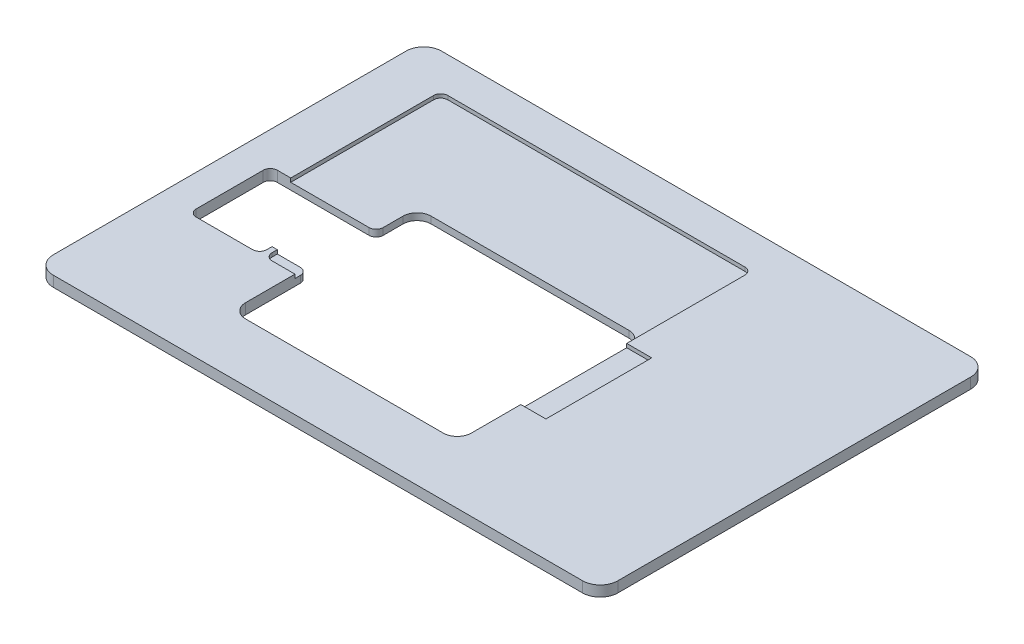
from build123d import *

# Parameters (mm, degrees)
SKETCH2_W           = 160
SKETCH2_H           = 110
BOSS_EXTRUDE1_DEPTH = 1.5
FILLET1_R           = 5
CUT_EXTRUDE1_DEPTH  = 4
FILLET2_R           = 2
FILLET3_R           = 4
CUT_EXTRUDE2_DEPTH  = 1.07
FILLET4_R           = 2


with BuildPart() as part:
    # Sketch2 → Boss-Extrude1 (new body, symmetric)
    with BuildSketch(Plane(origin=(0, 0, 0), x_dir=(1, 0, 0), z_dir=(0, 1, 0))):
        Rectangle(SKETCH2_W, SKETCH2_H)
    extrude(amount=BOSS_EXTRUDE1_DEPTH, both=True)

    # Fillet1
    fillet1_edges = [part.edges().sort_by_distance(p)[0] for p in [
        (80, 0, 55),
        (-80, 0, 55),
        (-80, 0, -55),
        (80, 0, -55),
    ]]
    fillet(fillet1_edges, radius=FILLET1_R)

    # Sketch3 → Cut-Extrude1 (cut, through all)
    with BuildSketch(Plane(origin=(0, 1.5, 0), x_dir=(1, 0, 0), z_dir=(0, 1, 0))):
        Polygon((-71, 2.5), (-51, 2.5), (-41, 2.5), (-41, 14.1), (23, 14.1), (23, -38.5), (-41, -38.5), (-41, -17), (-49.93, -17), (-51, -17), (-51, -20.5), (-71, -20.5), align=None)
    extrude(amount=-CUT_EXTRUDE1_DEPTH, mode=Mode.SUBTRACT)

    # Fillet2
    fillet2_edges = [part.edges().sort_by_distance(p)[0] for p in [
        (-51, 0, 20.5),
        (-71, 0, 20.5),
        (-71, 0, -2.5),
        (-41, 0, -2.5),
        (-41, 0, 17),
    ]]
    fillet(fillet2_edges, radius=FILLET2_R)

    # Fillet3
    fillet3_edges = [part.edges().sort_by_distance(p)[0] for p in [
        (-41, 0, -14.1),
        (23, 0, -14.1),
        (23, 0, 38.5),
        (-41, 0, 38.5),
    ]]
    fillet(fillet3_edges, radius=FILLET3_R)

    # Sketch4 → Cut-Extrude2 (cut)
    with BuildSketch(Plane(origin=(0, 1.5, 0), x_dir=(1, 0, 0), z_dir=(0, 1, 0))):
        with BuildLine():
            Line((-65.2, 2.5), (-65.2, 45))
            Line((-65.2, 45), (23, 45))
            Line((23, 45), (23, 10.1))
            ThreePointArc((23, 10.1), (21.828427125, 12.928427125), (19, 14.1))
            Line((19, 14.1), (-37, 14.1))
            ThreePointArc((-37, 14.1), (-39.828427125, 12.928427125), (-41, 10.1))
            Line((-41, 10.1), (-41, 9.5))
            Line((-41, 9.5), (30.1, 9.5))
            Line((30.1, 9.5), (30.1, -20.5))
            Line((30.1, -20.5), (-49.5, -20.5))
            Line((-49.5, -20.5), (-49.5, 2.5))
            Line((-49.5, 2.5), (-65.2, 2.5))
        make_face()
    extrude(amount=-CUT_EXTRUDE2_DEPTH, mode=Mode.SUBTRACT)

    # Fillet4
    fillet4_edges = [part.edges().sort_by_distance(p)[0] for p in [
        (-49.5, 0.965, 20.5),
        (-65.2, 0.965, -45),
        (23, 0.965, -45),
    ]]
    fillet(fillet4_edges, radius=FILLET4_R)


solid = part.part
